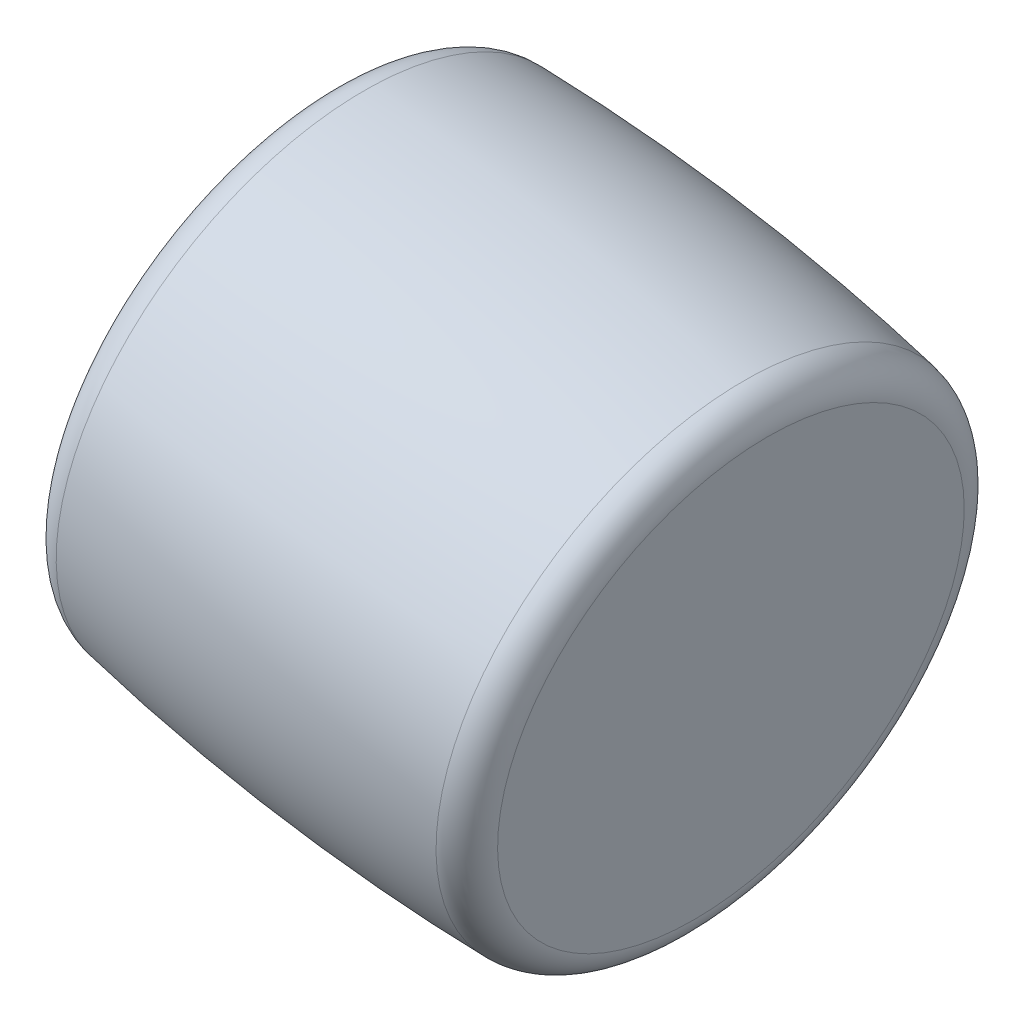
from build123d import *


with BuildPart() as part:
    # Sketch1 → Revolve1 (revolve)
    with BuildSketch(Plane.XY):
        with BuildLine():
            Line((15.915770545, 44.036433328), (16.768239868, 49.319190003))
            ThreePointArc((16.768239868, 49.319190003), (17.042578966, 49.787303624), (17.560848998, 49.947891537))
            ThreePointArc((17.560848998, 49.947891537), (22.003636887, 49.435542829), (26.382076147, 48.524425343))
            ThreePointArc((26.382076147, 48.524425343), (26.823527709, 48.208968814), (26.936698778, 47.678323346))
            Line((26.936698778, 47.678323346), (26.084229455, 42.395566672))
            Line((26.084229455, 42.395566672), (15.915770545, 44.036433328))
        make_face()
    revolve(axis=Axis((26.084229455, 42.395566672, 0), (-0.98722902, 0.159307442, 0)))


solid = part.part
